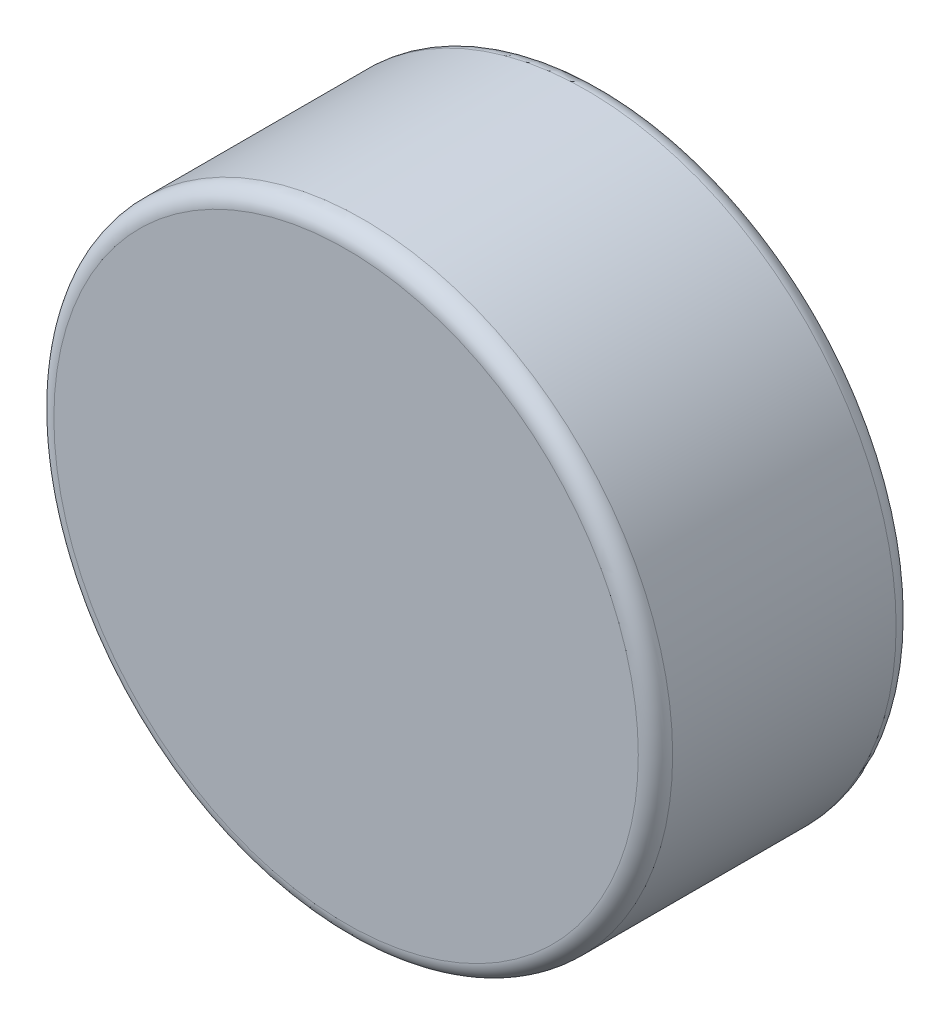
from build123d import *

# Parameters (mm, degrees)
SKETCH_1_R      = 3.6
EXTRUDE_1_DEPTH = 3
FILLET_1_R      = 0.2


with BuildPart() as part:
    # 草图1 → 凸台-拉伸1 (new body)
    with BuildSketch(Plane.XY):
        Circle(SKETCH_1_R)
    extrude(amount=EXTRUDE_1_DEPTH)

    # 圆角1
    fillet_1_edges = [part.edges().sort_by_distance(p)[0] for p in [
        (-3.6, 0, 0),
        (-3.6, 0, 3),
    ]]
    fillet(fillet_1_edges, radius=FILLET_1_R)


solid = part.part
